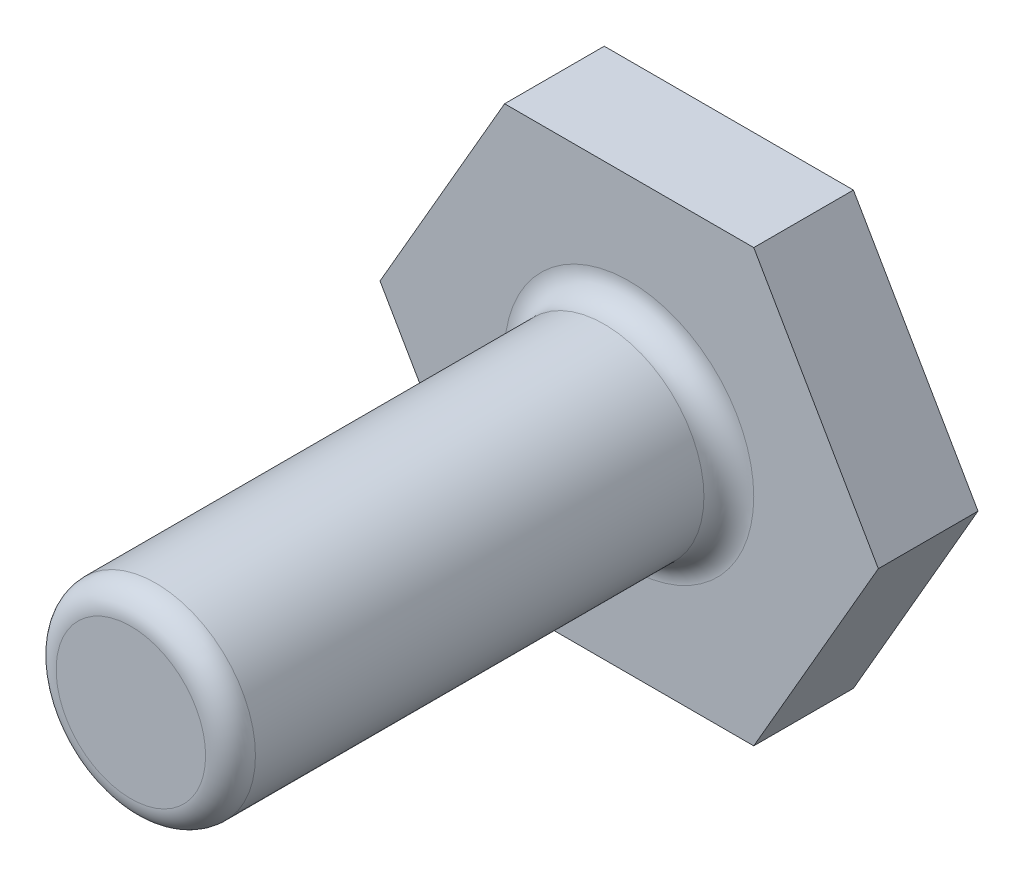
from build123d import *

# Parameters (mm, degrees)
BOSS_EXTRUDE1_DEPTH = 4
SKETCH3_R           = 4
BOSS_EXTRUDE2_DEPTH = 20
FILLET2_R           = 1


with BuildPart() as part:
    # Sketch2 → Boss-Extrude1 (new body)
    with BuildSketch(Plane.XY):
        Polygon((-10, 0), (-5, -8.660254038), (5, -8.660254038), (10, 0), (5, 8.660254038), (-5, 8.660254038), align=None)
    extrude(amount=BOSS_EXTRUDE1_DEPTH)

    # Sketch3 → Boss-Extrude2 (add)
    with BuildSketch(Plane.XY.offset(4)):
        Circle(SKETCH3_R)
    extrude(amount=BOSS_EXTRUDE2_DEPTH)

    # Fillet2
    fillet2_edges = [part.edges().sort_by_distance(p)[0] for p in [
        (-4, 0, 4),
        (-4, 0, 24),
    ]]
    fillet(fillet2_edges, radius=FILLET2_R)


solid = part.part
